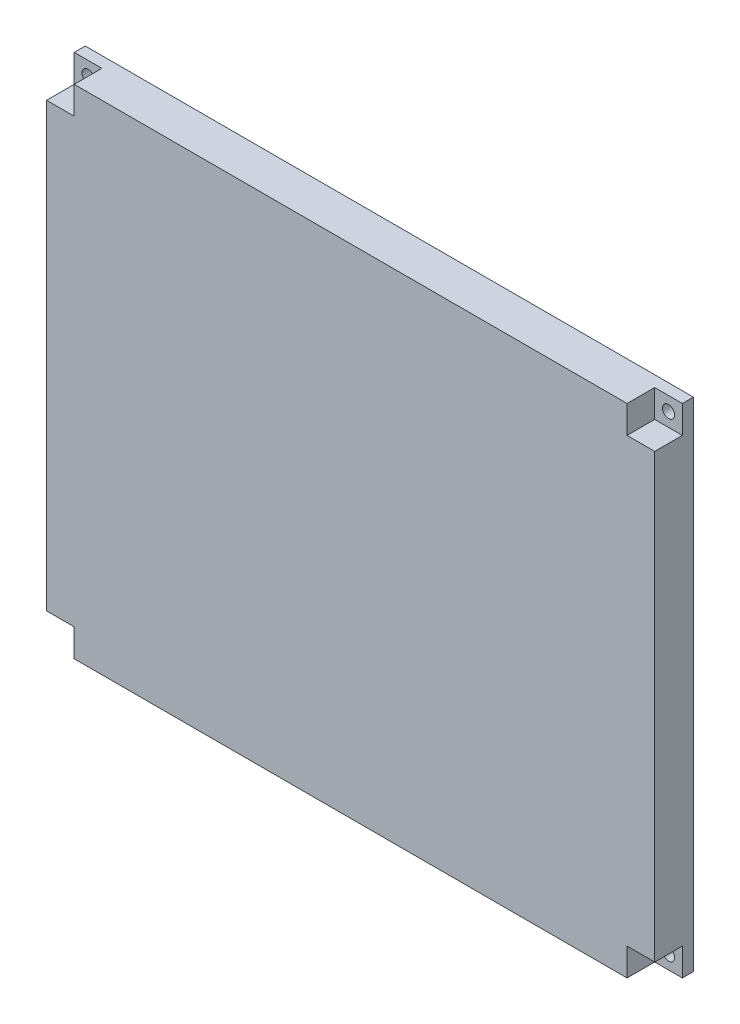
from build123d import *

# Parameters (mm, degrees)
SKETCH_1_W          = 120
SKETCH_1_H          = 90
EXTRUDE_1_DEPTH     = 10
SKETCH_6_W          = 5
SKETCH_6_H          = 5
CUT_EXTRUDE_4_DEPTH = 5
SKETCH_7_W          = 5
SKETCH_7_H          = 5
CUT_EXTRUDE_5_DEPTH = 3
SKETCH_8_R          = 1.1
CUT_EXTRUDE_6_DEPTH = 42
SKETCH_10_W         = 120
SKETCH_10_H         = 90
CUT_EXTRUDE_7_DEPTH = 3
SKETCH_11_W         = 7
SKETCH_11_H         = 90
CUT_EXTRUDE_8_DEPTH = 5
SKETCH_12_W         = 7
SKETCH_12_H         = 90
CUT_EXTRUDE_9_DEPTH = 5


with BuildPart() as part:
    # 草圖1 → 填料-伸長1 (new body)
    with BuildSketch(Plane.XY):
        with Locations((-29.08671555, -2.01863354)):
            Rectangle(SKETCH_1_W, SKETCH_1_H)
    extrude(amount=EXTRUDE_1_DEPTH)

    # 草圖6 → 除料-伸長4 (cut)
    with BuildSketch(Plane.XY.offset(10)):
        with Locations((23.41328445, 40.48136646)):
            Rectangle(SKETCH_6_W, SKETCH_6_H)
        with Locations((-81.58671555, 40.48136646)):
            Rectangle(SKETCH_6_W, SKETCH_6_H)
        with Locations((-81.58671555, -44.51863354)):
            Rectangle(SKETCH_6_W, SKETCH_6_H)
        with Locations((23.41328445, -44.51863354)):
            Rectangle(SKETCH_6_W, SKETCH_6_H)
    extrude(amount=-CUT_EXTRUDE_4_DEPTH, mode=Mode.SUBTRACT)

    # 草圖7 → 除料-伸長5 (cut)
    with BuildSketch(Plane(origin=(0, 0, 0), x_dir=(-1, 0, 0), z_dir=(0, 0, -1))):
        with Locations((81.58671555, 40.48136646)):
            Rectangle(SKETCH_7_W, SKETCH_7_H)
        with Locations((-23.41328445, 40.48136646)):
            Rectangle(SKETCH_7_W, SKETCH_7_H)
        with Locations((81.58671555, -44.51863354)):
            Rectangle(SKETCH_7_W, SKETCH_7_H)
        with Locations((-23.41328445, -44.51863354)):
            Rectangle(SKETCH_7_W, SKETCH_7_H)
    extrude(amount=-CUT_EXTRUDE_5_DEPTH, mode=Mode.SUBTRACT)

    # 草圖8 → 除料-伸長6 (cut)
    with BuildSketch(Plane(origin=(0, 0, 0), x_dir=(-1, 0, 0), z_dir=(0, 0, -1))):
        with Locations((-23.41328445, 40.48136646)):
            Circle(SKETCH_8_R)
        with Locations((81.58671555, 40.48136646)):
            Circle(SKETCH_8_R)
        with Locations((81.58671555, -44.51863354)):
            Circle(SKETCH_8_R)
        with Locations((-23.41328445, -44.51863354)):
            Circle(SKETCH_8_R)
    extrude(amount=-CUT_EXTRUDE_6_DEPTH, mode=Mode.SUBTRACT)

    # 草圖10 → 除料-伸長7 (cut)
    with BuildSketch(Plane.XY):
        with Locations((-29.08671555, -2.01863354)):
            Rectangle(SKETCH_10_W, SKETCH_10_H)
    extrude(amount=CUT_EXTRUDE_7_DEPTH, mode=Mode.SUBTRACT)

    # 草圖11 → 除料-伸長8 (cut)
    with BuildSketch(Plane(origin=(30.91328445, 0, 0), x_dir=(0, 0, -1), z_dir=(1, 0, 0))):
        with Locations((-6.5, -2.01863354)):
            Rectangle(SKETCH_11_W, SKETCH_11_H)
    extrude(amount=-CUT_EXTRUDE_8_DEPTH, mode=Mode.SUBTRACT)

    # 草圖12 → 除料-伸長9 (cut)
    with BuildSketch(Plane.ZY.offset(89.08671555)):
        with Locations((6.5, -2.01863354)):
            Rectangle(SKETCH_12_W, SKETCH_12_H)
    extrude(amount=-CUT_EXTRUDE_9_DEPTH, mode=Mode.SUBTRACT)


solid = part.part
